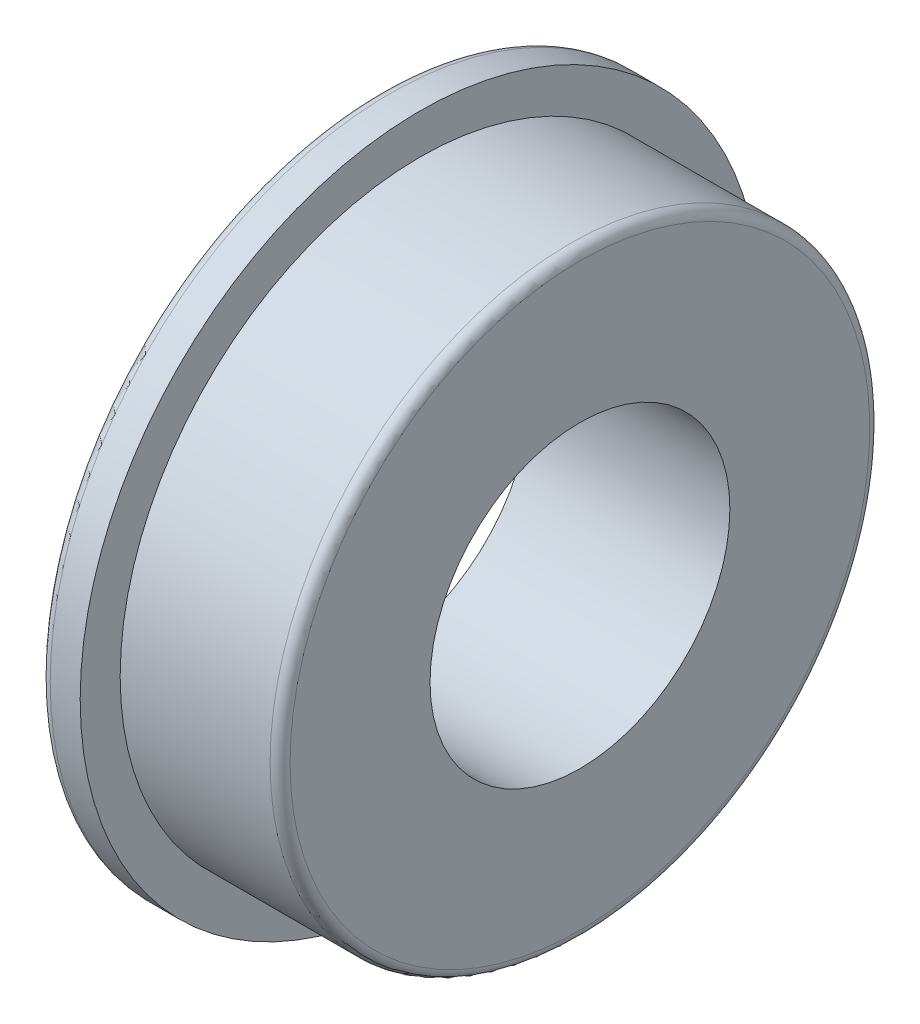
from build123d import *

# Parameters (mm, degrees)
FILLET1_R = 0.2


with BuildPart() as part:
    # Sketch1 → Revolve1 (revolve)
    with BuildSketch(Plane.XY):
        Polygon((0, 3), (0, 6.8), (0.8, 6.8), (0.8, 6), (4, 6), (4, 3), align=None)
    revolve(axis=Axis((0, 0, 0), (1, 0, 0)))

    # Fillet1
    fillet1_edges = [part.edges().sort_by_distance(p)[0] for p in [
        (4, -6, 0),
        (0, -6.8, 0),
    ]]
    fillet(fillet1_edges, radius=FILLET1_R)


solid = part.part
